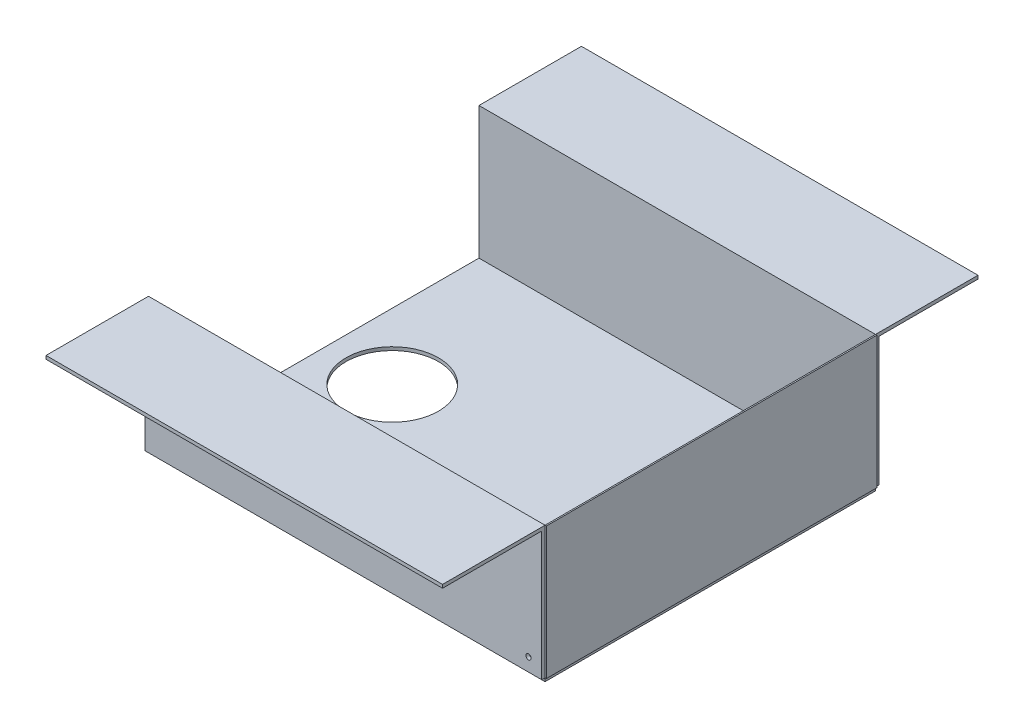
from build123d import *

# Parameters (mm, degrees)
SKETCH1_W               = 300
SKETCH1_H               = 250
BOSS_EXTRUDE1_DEPTH     = 2.54
SKETCH2_W               = 300
SKETCH2_H               = 2.54
EXTRUDE_THIN1_DEPTH     = 100
EXTRUDE_THIN1_2_DEPTH   = 100
SKETCH3_W               = 300
SKETCH3_H               = 2.54
EXTRUDE_THIN2_DEPTH     = 75
SKETCH4_W               = 300
SKETCH4_H               = 2.54
EXTRUDE_THIN3_DEPTH     = 75
SKETCH5_R               = 2
CUT_EXTRUDE1_DEPTH      = 331.08
SKETCH7_W               = 250
SKETCH7_H               = 100
BOSS_EXTRUDE2_DEPTH     = 1
SKETCH8_R               = 35
CUT_EXTRUDE2_DEPTH      = 101
CUT_EXTRUDE2_DEPTH_BACK = 3.54


with BuildPart() as part:
    # Sketch1 → Boss-Extrude1 (new body)
    with BuildSketch(Plane(origin=(0, 0, 0), x_dir=(1, 0, 0), z_dir=(0, 1, 0))):
        with Locations((12.333270701, -8.757097239)):
            Rectangle(SKETCH1_W, SKETCH1_H)
    extrude(amount=BOSS_EXTRUDE1_DEPTH)

    # Sketch8 → Cut-Extrude2 (cut, two sides)
    with BuildSketch(Plane(origin=(0, 2.54, 0), x_dir=(1, 0, 0), z_dir=(0, 1, 0))) as cut_extrude2_sk:
        with Locations((-87.666729299, 0.65318235)):
            Circle(SKETCH8_R)
    extrude(amount=CUT_EXTRUDE2_DEPTH, mode=Mode.SUBTRACT)
    extrude(cut_extrude2_sk.sketch, amount=-CUT_EXTRUDE2_DEPTH_BACK, mode=Mode.SUBTRACT)


with BuildPart() as body_2:
    # Sketch2 → Extrude-Thin1 (new body)
    with BuildSketch(Plane(origin=(0, 2.54, 0), x_dir=(1, 0, 0), z_dir=(0, 1, 0))):
        with Locations((12.333270701, -135.027097239)):
            Rectangle(SKETCH2_W, SKETCH2_H)
    extrude(amount=EXTRUDE_THIN1_DEPTH)

    # Sketch4 → Extrude-Thin3 (add)
    with BuildSketch(Plane.XY.offset(136.297097239)):
        with Locations((12.333270701, 101.27)):
            Rectangle(SKETCH4_W, SKETCH4_H)
    extrude(amount=EXTRUDE_THIN3_DEPTH)


with BuildPart() as body_3:
    # Sketch2 → Extrude-Thin1 2 (new body)
    with BuildSketch(Plane(origin=(0, 2.54, 0), x_dir=(1, 0, 0), z_dir=(0, 1, 0))):
        with Locations((12.333270701, 117.512902761)):
            Rectangle(SKETCH2_W, SKETCH2_H)
    extrude(amount=EXTRUDE_THIN1_2_DEPTH)

    # Sketch3 → Extrude-Thin2 (add)
    with BuildSketch(Plane(origin=(0, 0, -118.782902761), x_dir=(-1, 0, 0), z_dir=(0, 0, -1))):
        with Locations((-12.333270701, 101.27)):
            Rectangle(SKETCH3_W, SKETCH3_H)
    extrude(amount=EXTRUDE_THIN2_DEPTH)


with BuildPart() as cut_extrude1_tool:
    # Sketch5 → Cut-Extrude1 (new body, through all)
    with BuildSketch(Plane(origin=(0, 0, -118.782902761), x_dir=(-1, 0, 0), z_dir=(0, 0, -1))):
        with Locations((-152.333270701, 12.54)):
            Circle(SKETCH5_R)
    extrude(amount=-CUT_EXTRUDE1_DEPTH)


with BuildPart() as body_2_1:
    add(body_2.part)

    # Cut-Extrude1: cut by cut_extrude1_tool
    add(cut_extrude1_tool.part, mode=Mode.SUBTRACT)


with BuildPart() as body_3_1:
    add(body_3.part)

    # Cut-Extrude1: cut by cut_extrude1_tool
    add(cut_extrude1_tool.part, mode=Mode.SUBTRACT)


with BuildPart() as body_4:
    # Sketch7 → Boss-Extrude2 (new body)
    with BuildSketch(Plane(origin=(162.333270701, 0, 0), x_dir=(0, 0, -1), z_dir=(1, 0, 0))):
        with Locations((-8.757097239, 52.54)):
            Rectangle(SKETCH7_W, SKETCH7_H)
    extrude(amount=BOSS_EXTRUDE2_DEPTH)


solid = Compound([part.part, body_2_1.part, body_3_1.part, body_4.part])
